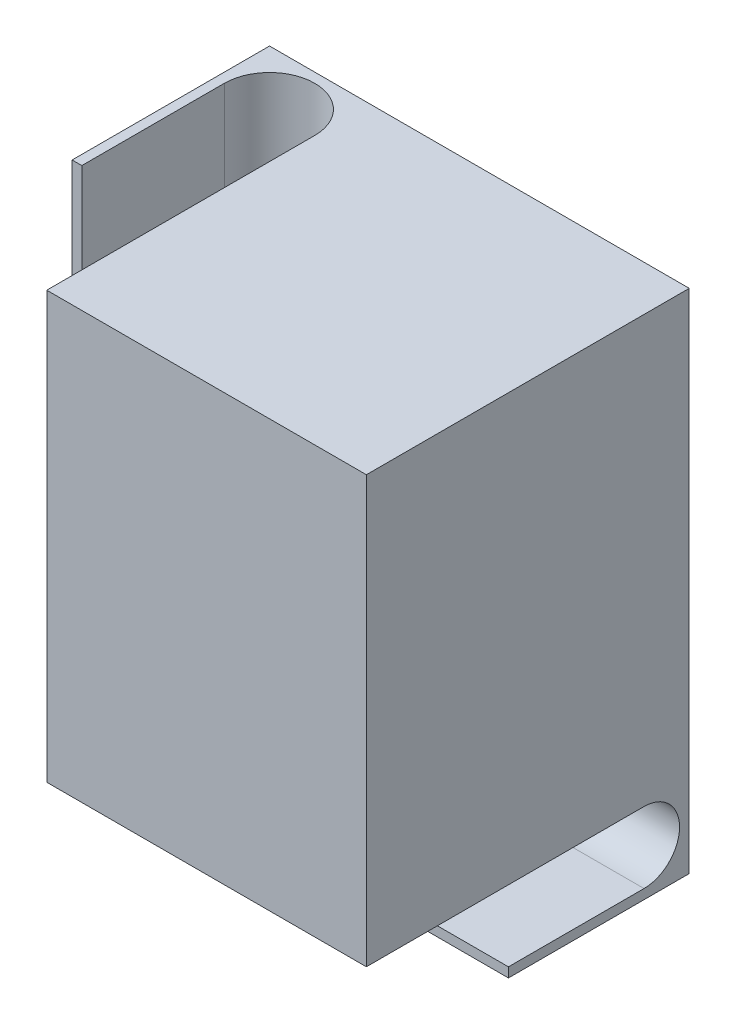
from build123d import *

# Parameters (mm, degrees)
SKETCH1_W           = 130
SKETCH1_H           = 157
BOSS_EXTRUDE1_DEPTH = 100
CUT_EXTRUDE3_DEPTH  = 130
CUT_EXTRUDE7_DEPTH  = 157
SKETCH10_W          = 31
SKETCH10_H          = 58.139222378
CUT_EXTRUDE8_DEPTH  = 25
SKETCH11_W          = 93
SKETCH11_H          = 126
CUT_EXTRUDE9_DEPTH  = 97


with BuildPart() as part:
    # Sketch1 → Boss-Extrude1 (new body)
    with BuildSketch(Plane.XY):
        with Locations((89.509803922, -21.637254902)):
            Rectangle(SKETCH1_W, SKETCH1_H)
    extrude(amount=BOSS_EXTRUDE1_DEPTH)

    # Sketch3 → Cut-Extrude3 (cut)
    with BuildSketch(Plane(origin=(154.509803922, 0, 0), x_dir=(0, 0, -1), z_dir=(1, 0, 0))):
        with BuildLine():
            Line((-14, -97.137254902), (-56, -97.137254902))
            Line((-56, -97.137254902), (-56, -100.137254902))
            Line((-56, -100.137254902), (-100, -100.137254902))
            Line((-100, -100.137254902), (-100, -75.137254902))
            Line((-100, -75.137254902), (-14, -75.137254902))
            ThreePointArc((-14, -75.137254902), (-3, -86.137254902), (-14, -97.137254902))
        make_face()
    extrude(amount=-CUT_EXTRUDE3_DEPTH, mode=Mode.SUBTRACT)

    # Sketch9 → Cut-Extrude7 (cut)
    with BuildSketch(Plane(origin=(0, 56.862745098, 0), x_dir=(1, 0, 0), z_dir=(0, 1, 0))):
        with BuildLine():
            Line((27.509803922, -17), (27.509803922, -61.139222378))
            Line((27.509803922, -61.139222378), (24.509803922, -61.139222378))
            Line((24.509803922, -61.139222378), (24.509803922, -100))
            Line((24.509803922, -100), (55.509803922, -100))
            Line((55.509803922, -100), (55.509803922, -17))
            ThreePointArc((55.509803922, -17), (41.509803922, -3), (27.509803922, -17))
        make_face()
    extrude(amount=-CUT_EXTRUDE7_DEPTH, mode=Mode.SUBTRACT)

    # Sketch10 → Cut-Extrude8 (cut)
    with BuildSketch(Plane.XZ.offset(100.137254902)):
        with Locations((40.009803922, 32.069611189)):
            Rectangle(SKETCH10_W, SKETCH10_H)
    extrude(amount=-CUT_EXTRUDE8_DEPTH, mode=Mode.SUBTRACT)

    # Sketch11 → Cut-Extrude9 (cut)
    with BuildSketch(Plane(origin=(0, 0, 0), x_dir=(-1, 0, 0), z_dir=(0, 0, -1))):
        with Locations((-105.009803922, -9.137254902)):
            Rectangle(SKETCH11_W, SKETCH11_H)
    extrude(amount=-CUT_EXTRUDE9_DEPTH, mode=Mode.SUBTRACT)


solid = part.part
